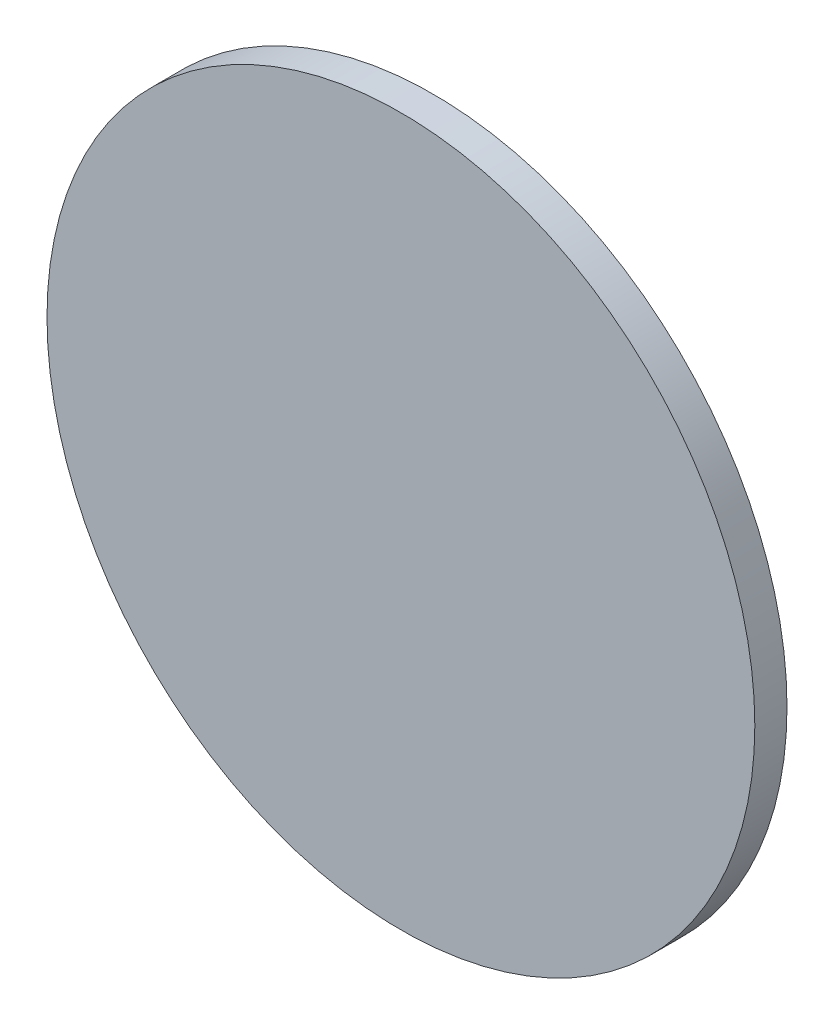
from build123d import *

# Parameters (mm, degrees)
SKETCH2_R           = 139.7
BOSS_EXTRUDE3_DEPTH = 12.7


with BuildPart() as part:
    # Sketch2 → Boss-Extrude3 (new body)
    with BuildSketch(Plane.XY):
        Circle(SKETCH2_R)
    extrude(amount=-BOSS_EXTRUDE3_DEPTH)


solid = part.part
